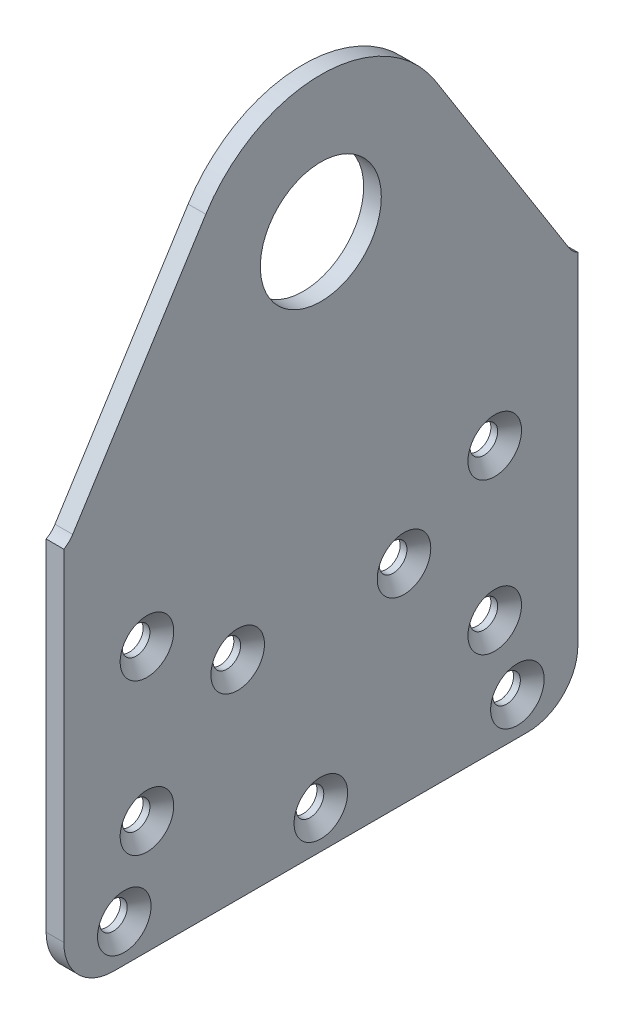
from build123d import *

# Parameters (mm, degrees)
SKETCH1_R                                 = 8
BOSS_EXTRUDE1_DEPTH                       = 2.3368
CSK_FOR_6_FLAT_HEAD_MACHINE_SCREW_2_COUNT = 2
CSK_FOR_6_FLAT_HEAD_MACHINE_SCREW_2_PITCH = 10.440306509
CSK_FOR_6_FLAT_HEAD_MACHINE_SCREW_3_COUNT = 2
CSK_FOR_6_FLAT_HEAD_MACHINE_SCREW_3_PITCH = 30.149626863
CSK_FOR_6_FLAT_HEAD_MACHINE_SCREW_4_COUNT = 2
CSK_FOR_6_FLAT_HEAD_MACHINE_SCREW_4_PITCH = 27.041634566
CSK_FOR_6_FLAT_HEAD_MACHINE_SCREW_5_COUNT = 2
CSK_FOR_6_FLAT_HEAD_MACHINE_SCREW_5_PITCH = 26
CSK_FOR_6_FLAT_HEAD_MACHINE_SCREW_6_COUNT = 2
CSK_FOR_6_FLAT_HEAD_MACHINE_SCREW_6_PITCH = 52
CSK_FOR_6_FLAT_HEAD_MACHINE_SCREW_7_COUNT = 2
CSK_FOR_6_FLAT_HEAD_MACHINE_SCREW_7_PITCH = 50.009999
CSK_FOR_6_FLAT_HEAD_MACHINE_SCREW_8_COUNT = 2
CSK_FOR_6_FLAT_HEAD_MACHINE_SCREW_8_PITCH = 43.304156844
CSK_FOR_6_FLAT_HEAD_MACHINE_SCREW_9_COUNT = 2
CSK_FOR_6_FLAT_HEAD_MACHINE_SCREW_9_PITCH = 57.454329689
FILLET1_R                                 = 6.6


with BuildPart() as part:
    # Sketch1 → Boss-Extrude1 (new body)
    with BuildSketch(Plane(origin=(0, 0, 0), x_dir=(0, 0, -1), z_dir=(1, 0, 0))):
        with BuildLine():
            Line((-15.217158613, 9.614472619), (-32.825001396, -18.254069638))
            ThreePointArc((-32.825001396, -18.254069638), (-33.341875677, -18.878440867), (-34, -19.351590767))
            Line((-34, -19.351590767), (-34, -71))
            Line((-34, -71), (34, -71))
            Line((34, -71), (34, -19.351590767))
            ThreePointArc((34, -19.351590767), (33.341875677, -18.878440867), (32.825001396, -18.254069638))
            Line((32.825001396, -18.254069638), (15.217158613, 9.614472619))
            ThreePointArc((15.217158613, 9.614472619), (0, 18), (-15.217158613, 9.614472619))
        make_face()
        Circle(SKETCH1_R, mode=Mode.SUBTRACT)
    extrude(amount=BOSS_EXTRUDE1_DEPTH)

    # Sketch4 → CSK for _6 Flat Head Machine Screw _100 (revolve, cut)
    with BuildSketch(Plane(origin=(2.3368, -66, 26), x_dir=(0, 0, -1), z_dir=(0, 1, 0))):
        Polygon((0, 0), (0, 2.3368), (1.8288, 2.3368), (1.8288, 1.438636318), (3.5433, 0), align=None)
    csk_for_6_flat_head_machine_screw_100 = revolve(axis=Axis((8.6868, -66, 26), (-1, 0, 0)), mode=Mode.SUBTRACT)

    # CSK for _6 Flat Head Machine Screw _ 2: CSK for _6 Flat Head Machine Screw _100 ×2
    with Locations(*[Vector(0, 0.9578262852211523, -0.2873478855663425) * (i * CSK_FOR_6_FLAT_HEAD_MACHINE_SCREW_2_PITCH) for i in range(1, CSK_FOR_6_FLAT_HEAD_MACHINE_SCREW_2_COUNT)]):
        add(csk_for_6_flat_head_machine_screw_100, mode=Mode.SUBTRACT)

    # CSK for _6 Flat Head Machine Screw _ 3: CSK for _6 Flat Head Machine Screw _100 ×2
    with Locations(*[Vector(0, 0.9950371902099893, -0.09950371902099815) * (i * CSK_FOR_6_FLAT_HEAD_MACHINE_SCREW_3_PITCH) for i in range(1, CSK_FOR_6_FLAT_HEAD_MACHINE_SCREW_3_COUNT)]):
        add(csk_for_6_flat_head_machine_screw_100, mode=Mode.SUBTRACT)

    # CSK for _6 Flat Head Machine Screw _ 4: CSK for _6 Flat Head Machine Screw _100 ×2
    with Locations(*[Vector(0, 0.832050294337844, -0.5547001962252285) * (i * CSK_FOR_6_FLAT_HEAD_MACHINE_SCREW_4_PITCH) for i in range(1, CSK_FOR_6_FLAT_HEAD_MACHINE_SCREW_4_COUNT)]):
        add(csk_for_6_flat_head_machine_screw_100, mode=Mode.SUBTRACT)

    # CSK for _6 Flat Head Machine Screw _ 5: CSK for _6 Flat Head Machine Screw _100 ×2
    with Locations(*[(0, 0, -i * CSK_FOR_6_FLAT_HEAD_MACHINE_SCREW_5_PITCH) for i in range(1, CSK_FOR_6_FLAT_HEAD_MACHINE_SCREW_5_COUNT)]):
        add(csk_for_6_flat_head_machine_screw_100, mode=Mode.SUBTRACT)

    # CSK for _6 Flat Head Machine Screw _ 6: CSK for _6 Flat Head Machine Screw _100 ×2
    with Locations(*[(0, 0, -i * CSK_FOR_6_FLAT_HEAD_MACHINE_SCREW_6_PITCH) for i in range(1, CSK_FOR_6_FLAT_HEAD_MACHINE_SCREW_6_COUNT)]):
        add(csk_for_6_flat_head_machine_screw_100, mode=Mode.SUBTRACT)

    # CSK for _6 Flat Head Machine Screw _ 7: CSK for _6 Flat Head Machine Screw _100 ×2
    with Locations(*[Vector(0, 0.19996001199600139, -0.9798040587804069) * (i * CSK_FOR_6_FLAT_HEAD_MACHINE_SCREW_7_PITCH) for i in range(1, CSK_FOR_6_FLAT_HEAD_MACHINE_SCREW_7_COUNT)]):
        add(csk_for_6_flat_head_machine_screw_100, mode=Mode.SUBTRACT)

    # CSK for _6 Flat Head Machine Screw _ 8: CSK for _6 Flat Head Machine Screw _100 ×2
    with Locations(*[Vector(0, 0.5195806047182286, -0.8544214388699759) * (i * CSK_FOR_6_FLAT_HEAD_MACHINE_SCREW_8_PITCH) for i in range(1, CSK_FOR_6_FLAT_HEAD_MACHINE_SCREW_8_COUNT)]):
        add(csk_for_6_flat_head_machine_screw_100, mode=Mode.SUBTRACT)

    # CSK for _6 Flat Head Machine Screw _ 9: CSK for _6 Flat Head Machine Screw _100 ×2
    with Locations(*[Vector(0, 0.52215385963853, -0.8528513040762653) * (i * CSK_FOR_6_FLAT_HEAD_MACHINE_SCREW_9_PITCH) for i in range(1, CSK_FOR_6_FLAT_HEAD_MACHINE_SCREW_9_COUNT)]):
        add(csk_for_6_flat_head_machine_screw_100, mode=Mode.SUBTRACT)

    # Fillet1
    fillet1_edges = [part.edges().sort_by_distance(p)[0] for p in [
        (1.1684, -71, -34),
        (1.1684, -71, 34),
    ]]
    fillet(fillet1_edges, radius=FILLET1_R)


solid = part.part
